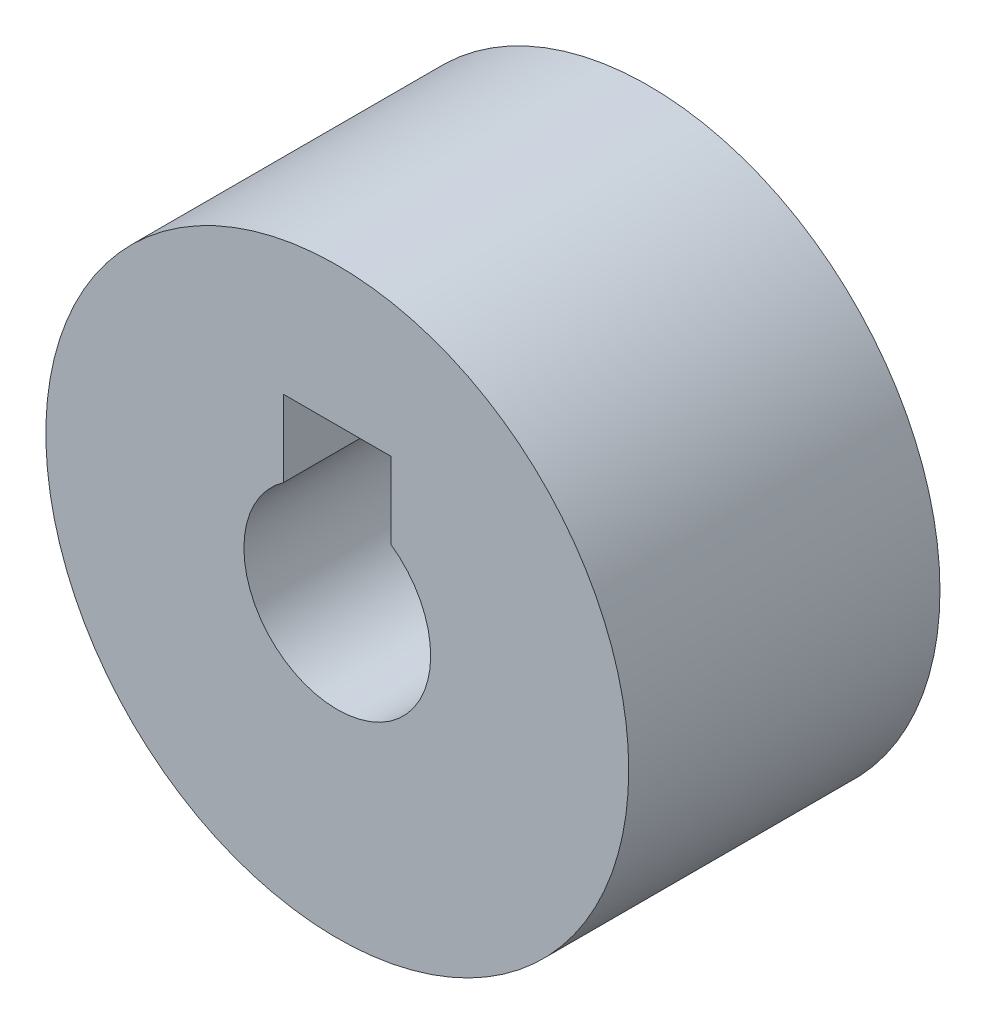
from build123d import *

# Parameters (mm, degrees)
SKETCH1_W           = 3.5
SKETCH1_H           = 3
CUT_EXTRUDE2_DEPTH  = 4
SKETCH7_R           = 5.15
BOSS_EXTRUDE3_DEPTH = 2.5


with BuildPart() as part:
    # Sketch1 → Revolve1 (revolve)
    with BuildSketch(Plane(origin=(0, 0, 0), x_dir=(1, 0, 0), z_dir=(0, 1, 0))):
        with Locations((3.4, 3.069926874)):
            Rectangle(SKETCH1_W, SKETCH1_H)
    revolve(axis=Axis((0, 0, 0), (0, 0, -1)))

    # Sketch6 → Cut-Extrude2 (cut)
    with BuildSketch(Plane.XY.offset(-1.569926874)):
        with BuildLine():
            Line((-0.95, 2.7), (-0.95, 1.349073756))
            ThreePointArc((-0.95, 1.349073756), (0, 1.65), (0.95, 1.349073756))
            Line((0.95, 1.349073756), (0.95, 2.7))
            Line((0.95, 2.7), (-0.95, 2.7))
        make_face()
    extrude(amount=-CUT_EXTRUDE2_DEPTH, mode=Mode.SUBTRACT)

    # Sketch7 → Boss-Extrude3 (add)
    with BuildSketch(Plane.XY.offset(-1.569926874)):
        Circle(SKETCH7_R)
        with BuildLine():
            Line((0.95, 2.7), (0.95, 1.349073756))
            ThreePointArc((0.95, 1.349073756), (0, -1.65), (-0.95, 1.349073756))
            Line((-0.95, 1.349073756), (-0.95, 2.7))
            Line((-0.95, 2.7), (0.95, 2.7))
        make_face(mode=Mode.SUBTRACT)
    extrude(amount=BOSS_EXTRUDE3_DEPTH)


solid = part.part
